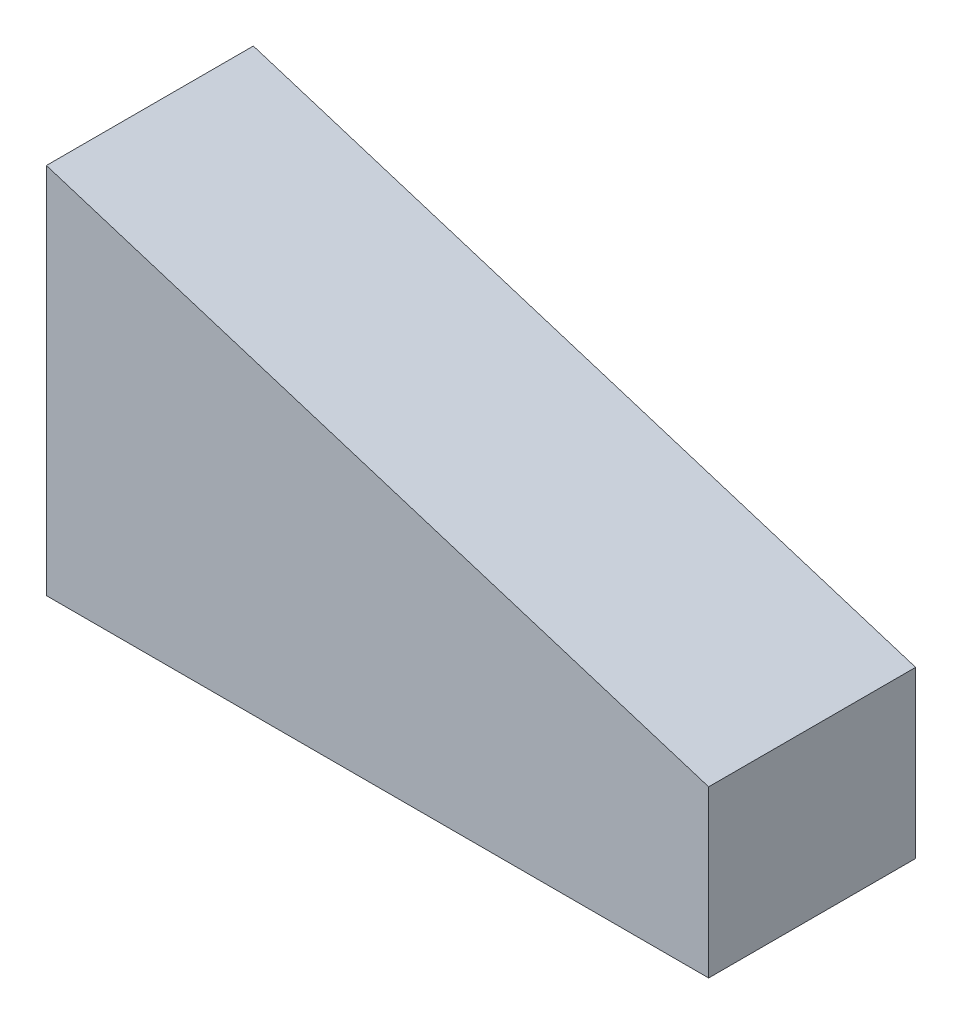
from build123d import *

# Parameters (mm, degrees)
BOSS_EXTRUDE2_DEPTH = 25


with BuildPart() as part:
    # Sketch1 → Boss-Extrude2 (new body)
    with BuildSketch(Plane.XY):
        Polygon((0, 0), (80, 0), (80, 20), (0, 45), align=None)
    extrude(amount=BOSS_EXTRUDE2_DEPTH)


solid = part.part
